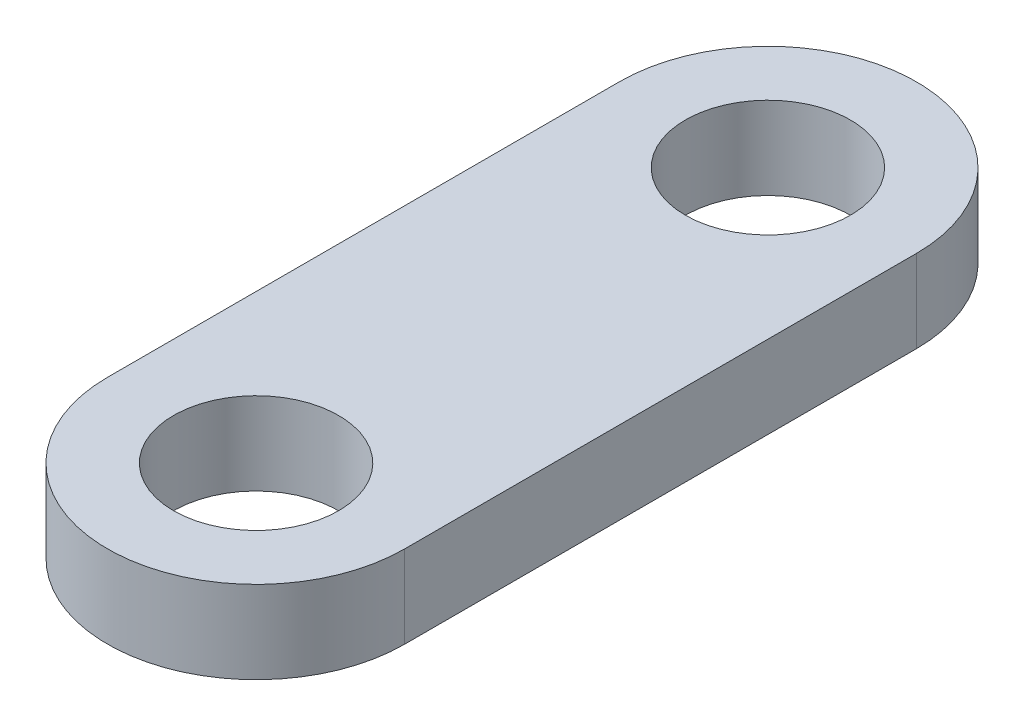
from build123d import *

# Parameters (mm, degrees)
SKETCH1_R           = 5
BOSS_EXTRUDE1_DEPTH = 5


with BuildPart() as part:
    # Sketch1 → Boss-Extrude1 (new body)
    with BuildSketch(Plane(origin=(0, 0, 0), x_dir=(1, 0, 0), z_dir=(0, 1, 0))):
        with BuildLine():
            Line((9, 0), (9, -31))
            ThreePointArc((9, -31), (0, -40), (-9, -31))
            Line((-9, -31), (-9, 0))
            ThreePointArc((-9, 0), (0, 9), (9, 0))
        make_face()
        Circle(SKETCH1_R, mode=Mode.SUBTRACT)
        with Locations((0, -31)):
            Circle(SKETCH1_R, mode=Mode.SUBTRACT)
    extrude(amount=BOSS_EXTRUDE1_DEPTH)


solid = part.part
